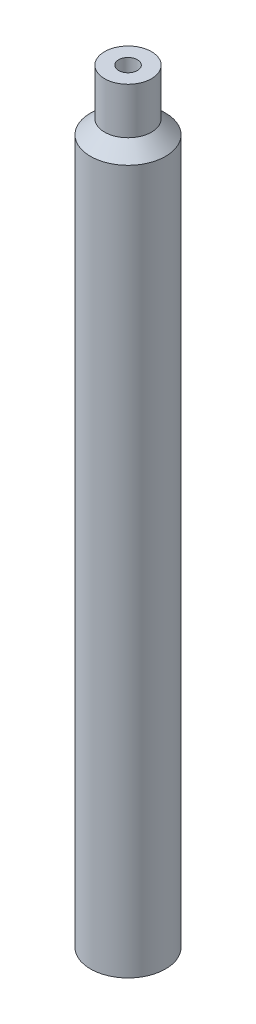
from build123d import *


with BuildPart() as part:
    # Эскиз1 → Повернуть1 (revolve)
    with BuildSketch(Plane(origin=(0, 0, 0), x_dir=(0, 0, -1), z_dir=(1, 0, 0))):
        Polygon((5, 150), (2, 152.963317198), (2, 162.837111471), (5, 162.837111471), (5, 152.963317198), (8, 150), (8, 0), (5, 0), align=None)
    revolve(axis=Axis((0, -19.35477628, 0), (0, 1, 0)))


solid = part.part
